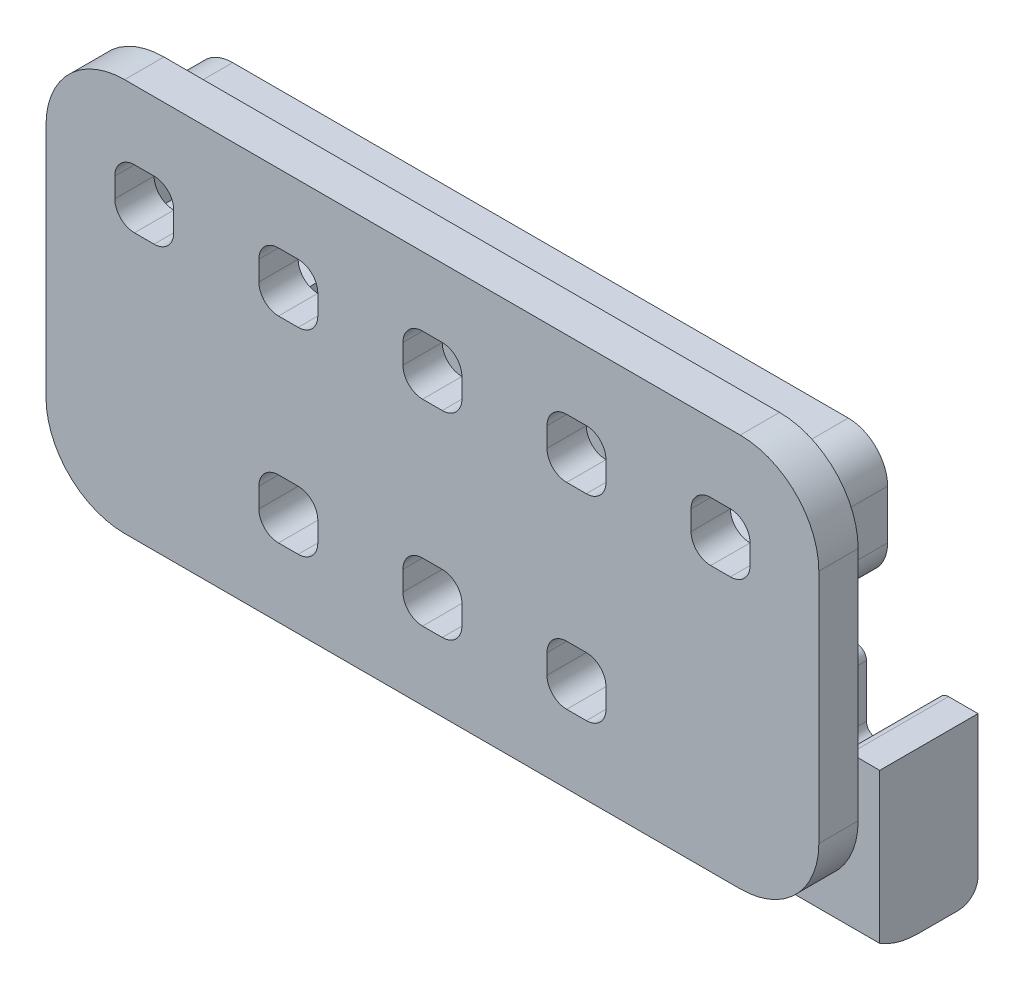
from build123d import *

# Parameters (mm, degrees)
BOSS_EXTRUDE1_DEPTH      = 10
SKETCH2_W                = 10
SKETCH2_H                = 6
BOSS_EXTRUDE2_DEPTH      = 23.975
SKETCH3_W                = 23.975
SKETCH3_H                = 6
BOSS_EXTRUDE4_DEPTH      = 2.2
BOSS_EXTRUDE4_DEPTH_BACK = 4
BOSS_EXTRUDE5_DEPTH      = 4
SKETCH5_W                = 78.65
SKETCH5_H                = 40
BOSS_EXTRUDE6_DEPTH      = 4
CUT_EXTRUDE1_DEPTH       = 79.65
FILLET1_R                = 2
SKETCH7_W                = 6
SKETCH7_H                = 6
CUT_EXTRUDE2_DEPTH       = 45
FILLET2_R                = 2
FILLET3_R                = 8
BOSS_EXTRUDE7_START      = 4
BOSS_EXTRUDE7_DEPTH      = 3
EXTRUDE_THIN1_DEPTH      = 4
FILLET4_R                = 4
FILLET5_R                = 1


with BuildPart() as part:
    # Sketch1 → Boss-Extrude1 (new body)
    with BuildSketch(Plane.XY):
        Polygon((0, 0), (-7.35, 0), (-7.35, 7.35), (-11.35, 7.35), (-11.35, -9), (4, -9), (4, 7.35), (0, 7.35), align=None)
    extrude(amount=BOSS_EXTRUDE1_DEPTH)

    # Sketch2 → Boss-Extrude2 (add)
    with BuildSketch(Plane(origin=(4, 0, 0), x_dir=(0, 0, -1), z_dir=(1, 0, 0))):
        with Locations((-5, -6)):
            Rectangle(SKETCH2_W, SKETCH2_H)
    extrude(amount=BOSS_EXTRUDE2_DEPTH)

    # Sketch3 → Boss-Extrude4 (add, two sides)
    with BuildSketch(Plane.XY.offset(10)) as boss_extrude4_sk:
        with BuildLine():
            Line((4, -2.735489451), (4, -3))
            Line((4, -3), (27.975, -3))
            Line((27.975, -3), (27.975, 5.85))
            Line((27.975, 5.85), (6.085603209, 5.85))
            ThreePointArc((6.085603209, 5.85), (6.264970626, 4.769067619), (6.325, 3.675))
            ThreePointArc((6.325, 3.675), (5.725797838, 0.265454576), (4, -2.735489451))
        make_face()
        with Locations((15.9875, -6)):
            Rectangle(SKETCH3_W, SKETCH3_H)
    extrude(amount=BOSS_EXTRUDE4_DEPTH)
    extrude(boss_extrude4_sk.sketch, amount=-BOSS_EXTRUDE4_DEPTH_BACK)

    # Sketch3_3 → Boss-Extrude5 (add)
    with BuildSketch(Plane.XY.offset(10)):
        with BuildLine():
            Line((4, 5.85), (4, -2.735489451))
            ThreePointArc((4, -2.735489451), (5.725797838, 0.265454576), (6.325, 3.675))
            ThreePointArc((6.325, 3.675), (6.264970626, 4.769067619), (6.085603209, 5.85))
            Line((6.085603209, 5.85), (4, 5.85))
        make_face()
    extrude(amount=-BOSS_EXTRUDE5_DEPTH)

    # Mirror1: part across plane


with BuildPart() as part_1:
    add(part.part)
    add(part.part.mirror(Plane.ZY.offset(-27.975)))

    # Sketch5 → Boss-Extrude6 (add)
    with BuildSketch(Plane.XY.offset(12.2)):
        with Locations((27.975, 16)):
            Rectangle(SKETCH5_W, SKETCH5_H)
    extrude(amount=BOSS_EXTRUDE6_DEPTH)

    # Sketch6 → Cut-Extrude1 (cut, through all)
    with BuildSketch(Plane(origin=(67.3, 0, 0), x_dir=(0, 0, -1), z_dir=(1, 0, 0))):
        with BuildLine():
            Line((-12.2, -9), (-10, -9))
            Line((-10, -9), (-10, -7.906246951))
            ThreePointArc((-10, -7.906246951), (-11.20325575, -6.996069572), (-12.2, -5.863484846))
            Line((-12.2, -5.863484846), (-12.2, -9))
        make_face()
        with BuildLine():
            Line((-10, -9), (-6.1, -9))
            ThreePointArc((-6.1, -9), (-8.125234291, -8.721386714), (-10, -7.906246951))
            Line((-10, -7.906246951), (-10, -9))
        make_face()
    extrude(amount=-CUT_EXTRUDE1_DEPTH, mode=Mode.SUBTRACT)

    # Fillet1
    fillet1_edges = [part_1.edges().sort_by_distance(p)[0] for p in [
        (27.975, -9, 0),
    ]]
    fillet(fillet1_edges, radius=FILLET1_R)

    # Sketch7 → Cut-Extrude2 (cut)
    with BuildSketch(Plane.XY.offset(16.2)):
        with Locations((-1.35, 26)):
            Rectangle(SKETCH7_W, SKETCH7_H)
        with Locations((13.3125, 26)):
            Rectangle(SKETCH7_W, SKETCH7_H)
        with Locations((27.975, 26)):
            Rectangle(SKETCH7_W, SKETCH7_H)
        with Locations((42.6375, 26)):
            Rectangle(SKETCH7_W, SKETCH7_H)
        with Locations((13.3125, 6)):
            Rectangle(SKETCH7_W, SKETCH7_H)
        with Locations((27.975, 6)):
            Rectangle(SKETCH7_W, SKETCH7_H)
        with Locations((42.6375, 6)):
            Rectangle(SKETCH7_W, SKETCH7_H)
        with Locations((57.3, 26)):
            Rectangle(SKETCH7_W, SKETCH7_H)
    extrude(amount=-CUT_EXTRUDE2_DEPTH, mode=Mode.SUBTRACT)

    # Fillet2
    fillet2_edges = [part_1.edges().sort_by_distance(p)[0] for p in [
        (-4.35, 23, 14.2),
        (-4.35, 29, 14.2),
        (1.65, 29, 14.2),
        (1.65, 23, 14.2),
        (54.3, 29, 14.2),
        (60.3, 29, 14.2),
        (60.3, 23, 14.2),
        (54.3, 23, 14.2),
        (45.6375, 9, 14.2),
        (45.6375, 3, 11.1),
        (39.6375, 3, 11.1),
        (39.6375, 9, 14.2),
        (30.975, 9, 14.2),
        (30.975, 3, 11.1),
        (24.975, 3, 11.1),
        (24.975, 9, 14.2),
        (10.3125, 29, 14.2),
        (16.3125, 29, 14.2),
        (16.3125, 23, 14.2),
        (10.3125, 23, 14.2),
        (24.975, 29, 14.2),
        (30.975, 29, 14.2),
        (30.975, 23, 14.2),
        (24.975, 23, 14.2),
        (39.6375, 29, 14.2),
        (45.6375, 29, 14.2),
        (45.6375, 23, 14.2),
        (39.6375, 23, 14.2),
        (16.3125, 9, 14.2),
        (16.3125, 3, 11.1),
        (10.3125, 3, 11.1),
        (10.3125, 9, 14.2),
    ]]
    fillet(fillet2_edges, radius=FILLET2_R)

    # Fillet3
    fillet3_edges = [part_1.edges().sort_by_distance(p)[0] for p in [
        (-11.35, 36, 14.2),
        (-11.35, -4, 14.2),
        (67.3, -4, 14.2),
        (67.3, 36, 14.2),
    ]]
    fillet(fillet3_edges, radius=FILLET3_R)

    # Sketch8 → Boss-Extrude7 (add)
    with BuildSketch(Plane(origin=(0, 0, 12.2), x_dir=(-1, 0, 0), z_dir=(0, 0, -1)).offset(BOSS_EXTRUDE7_START)):
        Polygon((-63.3, 32), (7.35, 32), (7.35, 19), (-7.3125, 19), (-7.3125, 0), (-48.6375, 0), (-48.6375, 19), (-63.3, 19), align=None)
    extrude(amount=BOSS_EXTRUDE7_DEPTH)

    # Sketch8_2 → Extrude-Thin1 (add)
    with BuildSketch(Plane(origin=(0, 0, 12.2), x_dir=(-1, 0, 0), z_dir=(0, 0, -1))):
        Polygon((-48.6375, 0), (-48.6375, 19), (-63.3, 19), (-63.3, 32), (7.35, 32), (7.35, 19), (-7.3125, 19), (-7.3125, 0), (-9.3125, 0), (-9.3125, 21), (5.35, 21), (5.35, 30), (-61.3, 30), (-61.3, 21), (-46.6375, 21), (-46.6375, 0), align=None)
    extrude(amount=EXTRUDE_THIN1_DEPTH)

    # Fillet4
    fillet4_edges = [part_1.edges().sort_by_distance(p)[0] for p in [
        (48.6375, 19, 8.7),
        (48.6375, 0, 5.6),
        (7.3125, 0, 5.6),
        (63.3, 32, 8.7),
        (63.3, 19, 8.7),
        (7.3125, 19, 8.7),
        (-7.35, 19, 8.7),
        (-7.35, 32, 8.7),
    ]]
    fillet(fillet4_edges, radius=FILLET4_R)

    # Fillet5
    fillet5_edges = [part_1.edges().sort_by_distance(p)[0] for p in [
        (0, 7.35, 5),
        (0, 0, 5),
        (-7.35, 0, 5),
        (-7.35, 7.35, 5),
        (55.95, 7.35, 5),
        (55.95, 0, 5),
        (63.3, 0, 5),
        (63.3, 7.35, 5),
    ]]
    fillet(fillet5_edges, radius=FILLET5_R)


solid = part_1.part
